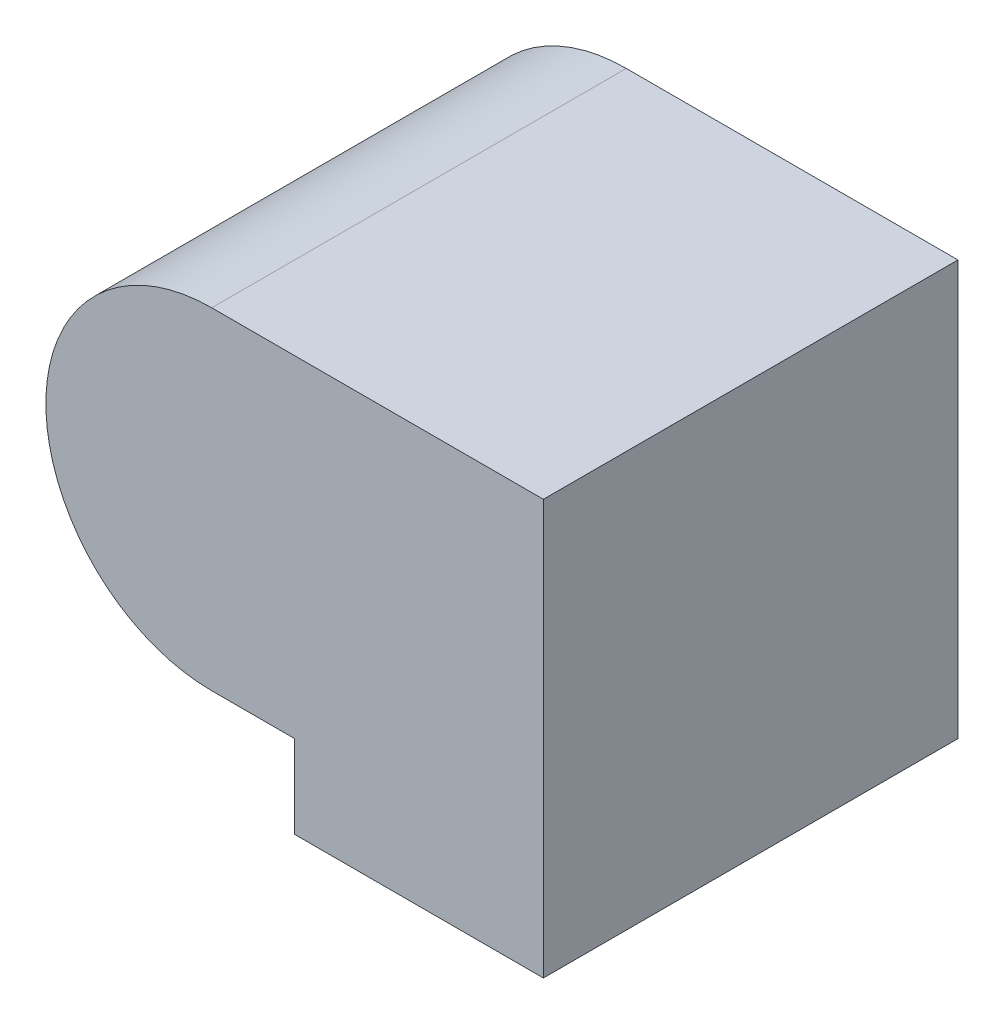
from build123d import *

# Parameters (mm, degrees)
SKETCH1_W           = 15
SKETCH1_H           = 25
BOSS_EXTRUDE1_DEPTH = 25


with BuildPart() as part:
    # Sketch1 → Boss-Extrude1 (new body)
    with BuildSketch(Plane.XY):
        with BuildLine():
            Line((0, -20), (0, 0))
            Line((0, 0), (-5, 0))
            ThreePointArc((-5, 0), (-15, -10), (-5, -20))
            Line((-5, -20), (0, -20))
        make_face()
        with Locations((7.5, -12.5)):
            Rectangle(SKETCH1_W, SKETCH1_H)
    extrude(amount=BOSS_EXTRUDE1_DEPTH)


solid = part.part
